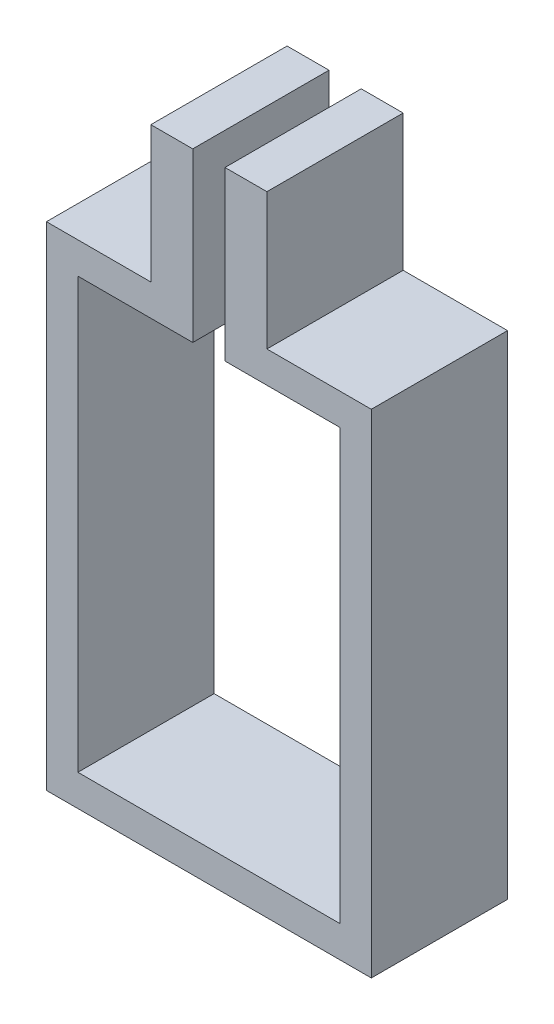
from build123d import *

# Parameters (mm, degrees)
CROQUIS1_W              = 31
CROQUIS1_H              = 47
SALIENTE_EXTRUIR1_DEPTH = 13
CROQUIS2_W              = 25
CROQUIS2_H              = 41
CORTAR_EXTRUIR1_DEPTH   = 13
CROQUIS3_W              = 3.075448652
CROQUIS3_H              = 33.686173061
CORTAR_EXTRUIR2_DEPTH   = 13
CROQUIS4_W              = 4
CROQUIS4_H              = 13
SALIENTE_EXTRUIR2_DEPTH = 13


with BuildPart() as part:
    # Croquis1 → Saliente-Extruir1 (new body)
    with BuildSketch(Plane.XY):
        Rectangle(CROQUIS1_W, CROQUIS1_H)
    extrude(amount=SALIENTE_EXTRUIR1_DEPTH)

    # Croquis2 → Cortar-Extruir1 (cut)
    with BuildSketch(Plane.XY.offset(13)):
        Rectangle(CROQUIS2_W, CROQUIS2_H)
    extrude(amount=-CORTAR_EXTRUIR1_DEPTH, mode=Mode.SUBTRACT)

    # Croquis3 → Cortar-Extruir2 (cut)
    with BuildSketch(Plane(origin=(0, 23.5, 0), x_dir=(1, 0, 0), z_dir=(0, 1, 0))):
        with Locations((0, -5.988894029)):
            Rectangle(CROQUIS3_W, CROQUIS3_H)
    extrude(amount=-CORTAR_EXTRUIR2_DEPTH, mode=Mode.SUBTRACT)

    # Croquis4 → Saliente-Extruir2 (add)
    with BuildSketch(Plane(origin=(0, 23.5, 0), x_dir=(1, 0, 0), z_dir=(0, 1, 0))):
        with Locations((3.537724326, -6.5)):
            Rectangle(CROQUIS4_W, CROQUIS4_H)
        with Locations((-3.537724326, -6.5)):
            Rectangle(CROQUIS4_W, CROQUIS4_H)
    extrude(amount=SALIENTE_EXTRUIR2_DEPTH)


solid = part.part
